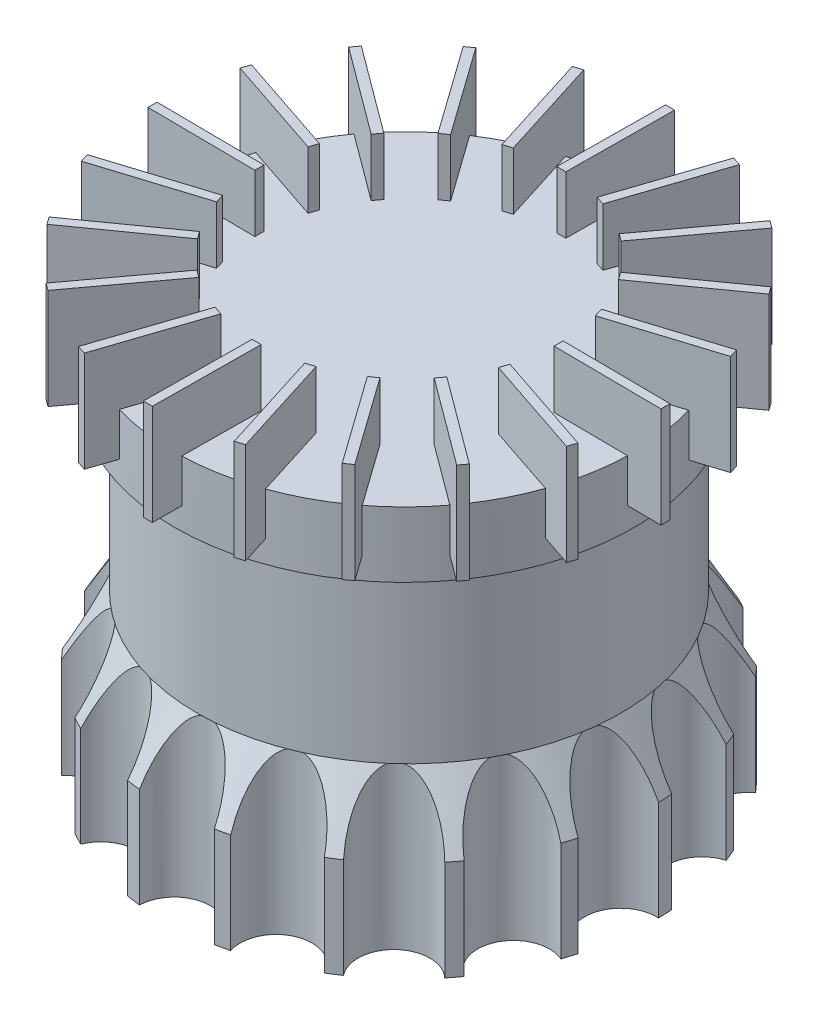
from build123d import *
from build123d.topology import SkipClean

# Parameters (mm, degrees)
SKETCH1_R                = 43.40225
BOSS_EXTRUDE1_DEPTH      = 28.702
SKETCH2_R                = 6.35
CUT_EXTRUDE1_DEPTH       = 80.8736
SKETCH3_OUTSIDE_W        = 207.328
SKETCH3_OUTSIDE_H        = 206.884
SKETCH3_OUTSIDE_R        = 37.05225
CUT_EXTRUDE2_DEPTH       = 80.8736
CUT_EXTRUDE2_DRAFT       = -30
SKETCH4_R                = 37.4269
BOSS_EXTRUDE2_DEPTH      = 29.59608
SKETCH5_R                = 40.597148096
BOSS_EXTRUDE3_DEPTH      = 11.5443
BOSS_EXTRUDE4_DEPTH      = 10.16
BOSS_EXTRUDE4_DEPTH_BACK = 7.62
SCALE1_SCALE             = 0.06


with BuildPart() as part:
    # Sketch1 → Boss-Extrude1 (new body)
    with BuildSketch(Plane(origin=(0, 0, 0), x_dir=(1, 0, 0), z_dir=(0, 1, 0))):
        Circle(SKETCH1_R)
    extrude(amount=BOSS_EXTRUDE1_DEPTH)

    # Sketch2 → Cut-Extrude1 (cut)
    with BuildSketch(Plane(origin=(0, 28.702, 0), x_dir=(1, 0, 0), z_dir=(0, 1, 0))):
        with Locations((-36.596730633, -23.333122637)):
            Circle(SKETCH2_R)
        with Locations((-42.37007567, -9.409144106)):
            Circle(SKETCH2_R)
        with Locations((-43.032964265, 5.649716069)):
            Circle(SKETCH2_R)
        with Locations((-38.50544227, 20.027137105)):
            Circle(SKETCH2_R)
        with Locations((-29.333595658, 31.988989837)):
            Circle(SKETCH2_R)
        with Locations((-16.623684492, 40.092498288)):
            Circle(SKETCH2_R)
        with Locations((-1.908711637, 43.360259743)):
            Circle(SKETCH2_R)
        with Locations((13.036480011, 41.398133943)):
            Circle(SKETCH2_R)
        with Locations((26.409279772, 34.442782219)):
            Circle(SKETCH2_R)
        with Locations((36.596730633, 23.333122637)):
            Circle(SKETCH2_R)
        with Locations((42.37007567, 9.409144106)):
            Circle(SKETCH2_R)
        with Locations((43.032964265, -5.649716069)):
            Circle(SKETCH2_R)
        with Locations((38.50544227, -20.027137105)):
            Circle(SKETCH2_R)
        with Locations((29.333595658, -31.988989837)):
            Circle(SKETCH2_R)
        with Locations((16.623684492, -40.092498288)):
            Circle(SKETCH2_R)
        with Locations((1.908711637, -43.360259743)):
            Circle(SKETCH2_R)
        with Locations((-13.036480011, -41.398133943)):
            Circle(SKETCH2_R)
        with Locations((-26.409279772, -34.442782219)):
            Circle(SKETCH2_R)
    extrude(amount=-CUT_EXTRUDE1_DEPTH, mode=Mode.SUBTRACT)


with BuildPart() as cut_extrude2_tool:
    # Sketch3 outside → Cut-Extrude2 (with draft: the straight prism first)
    with BuildSketch(Plane(origin=(0, 28.702, 0), x_dir=(1, 0, 0), z_dir=(0, 1, 0))):
        Rectangle(SKETCH3_OUTSIDE_W, SKETCH3_OUTSIDE_H)
        Circle(SKETCH3_OUTSIDE_R, mode=Mode.SUBTRACT)
    extrude(amount=-CUT_EXTRUDE2_DEPTH)
    # Cut-Extrude2: the draft: its side faces are tilted about the plane it starts from
    cut_extrude2_sides = [cut_extrude2_tool.faces().sort_by_distance(p)[0] for p in [
        (0, -11.7348, 103.442),
        (103.664, -11.7348, 0),
        (0, -11.7348, -103.442),
        (-103.664, -11.7348, 0),
        (-37.05225, -11.7348, 0),
    ]]
    draft(cut_extrude2_sides, Plane(origin=(0, 28.702, 0), x_dir=(1, 0, 0), z_dir=(0, 1, 0)), CUT_EXTRUDE2_DRAFT)


with BuildPart() as part_1:
    add(part.part)

    # Cut-Extrude2: cut by cut_extrude2_tool
    add(cut_extrude2_tool.part, mode=Mode.SUBTRACT)

    # Sketch4 → Boss-Extrude2 (add)
    with SkipClean():  # the faces are left unmerged after this step: merging them gives an invalid solid
        with BuildSketch(Plane(origin=(0, 28.702, 0), x_dir=(1, 0, 0), z_dir=(0, 1, 0))):
            Circle(SKETCH4_R)
        extrude(amount=BOSS_EXTRUDE2_DEPTH)

    # Sketch5 → Boss-Extrude3 (add)
    with SkipClean():  # the faces are left unmerged after this step: merging them gives an invalid solid
        with BuildSketch(Plane(origin=(0, 58.29808, 0), x_dir=(1, 0, 0), z_dir=(0, 1, 0))):
            with Locations((-0.8, 0)):
                Circle(SKETCH5_R)
        extrude(amount=BOSS_EXTRUDE3_DEPTH)

    # Sketch7 → Boss-Extrude4 (add, two sides: drawn at the far end of the back side and taken through both)
    with SkipClean():  # the faces are left unmerged after this step: merging them gives an invalid solid
        with BuildSketch(Plane(origin=(0, 69.84238, 0), x_dir=(1, 0, 0), z_dir=(0, 1, 0)).offset(-BOSS_EXTRUDE4_DEPTH_BACK)):
            Polygon((-16.51222471, -20.958896324), (-27.847408741, -36.269549575), (-26.56147461, -37.22158603), (-15.226290578, -21.910932779), align=None)
            Polygon((-21.251913465, -16.133352847), (-36.763566151, -27.19188489), (-37.692366742, -25.889068917), (-22.180714056, -14.830536873), align=None)
            Polygon((-25.19725099, -8.776527931), (-43.36698369, -14.500452601), (-43.847733269, -12.974385812), (-25.678000569, -7.250461143), align=None)
            Polygon((-26.676106029, -0.560595312), (-45.72533871, -0.38961498), (-45.710978157, 1.210320573), (-26.661745477, 1.039340241), align=None)
            Polygon((-25.543717947, 7.710212282), (-43.60777899, 13.759360869), (-43.099714017, 15.276552348), (-25.035652974, 9.227403761), align=None)
            Polygon((-21.910932779, 15.226290578), (-37.22158603, 26.56147461), (-36.269549575, 27.847408741), (-20.958896324, 16.51222471), align=None)
            Polygon((-16.133352847, 21.251913465), (-27.19188489, 36.763566151), (-25.889068917, 37.692366742), (-14.830536873, 22.180714056), align=None)
            Polygon((-8.776527931, 25.19725099), (-14.500452601, 43.36698369), (-12.974385812, 43.847733269), (-7.250461143, 25.678000569), align=None)
            Polygon((-0.560595312, 26.676106029), (-0.38961498, 45.72533871), (1.210320573, 45.710978157), (1.039340241, 26.661745477), align=None)
            Polygon((7.710212282, 25.543717947), (13.759360869, 43.60777899), (15.276552348, 43.099714017), (9.227403761, 25.035652974), align=None)
            Polygon((15.226290578, 21.910932779), (26.56147461, 37.22158603), (27.847408741, 36.269549575), (16.51222471, 20.958896324), align=None)
            Polygon((21.251913465, 16.133352847), (36.763566151, 27.19188489), (37.692366742, 25.889068917), (22.180714056, 14.830536873), align=None)
            Polygon((25.19725099, 8.776527931), (43.36698369, 14.500452601), (43.847733269, 12.974385812), (25.678000569, 7.250461143), align=None)
            Polygon((26.676106029, 0.560595312), (45.72533871, 0.38961498), (45.710978157, -1.210320573), (26.661745477, -1.039340241), align=None)
            Polygon((25.543717947, -7.710212282), (43.60777899, -13.759360869), (43.099714017, -15.276552348), (25.035652974, -9.227403761), align=None)
            Polygon((21.910932779, -15.226290578), (37.22158603, -26.56147461), (36.269549575, -27.847408741), (20.958896324, -16.51222471), align=None)
            Polygon((16.133352847, -21.251913465), (27.19188489, -36.763566151), (25.889068917, -37.692366742), (14.830536873, -22.180714056), align=None)
            Polygon((8.776527931, -25.19725099), (14.500452601, -43.36698369), (12.974385812, -43.847733269), (7.250461143, -25.678000569), align=None)
            Polygon((0.560595312, -26.676106029), (0.38961498, -45.72533871), (-1.210320573, -45.710978157), (-1.039340241, -26.661745477), align=None)
            Polygon((-7.710212282, -25.543717947), (-13.759360869, -43.60777899), (-15.276552348, -43.099714017), (-9.227403761, -25.035652974), align=None)
        extrude(amount=BOSS_EXTRUDE4_DEPTH + BOSS_EXTRUDE4_DEPTH_BACK)


with BuildPart() as part_2:
    # Scale1: scaled about (-0.131463209, 35.89050923, -3.107e-06)
    add(part_1.part.scale(SCALE1_SCALE).moved(Location((-0.123575416, 33.737078676, -2.921e-06))))


solid = part_2.part
